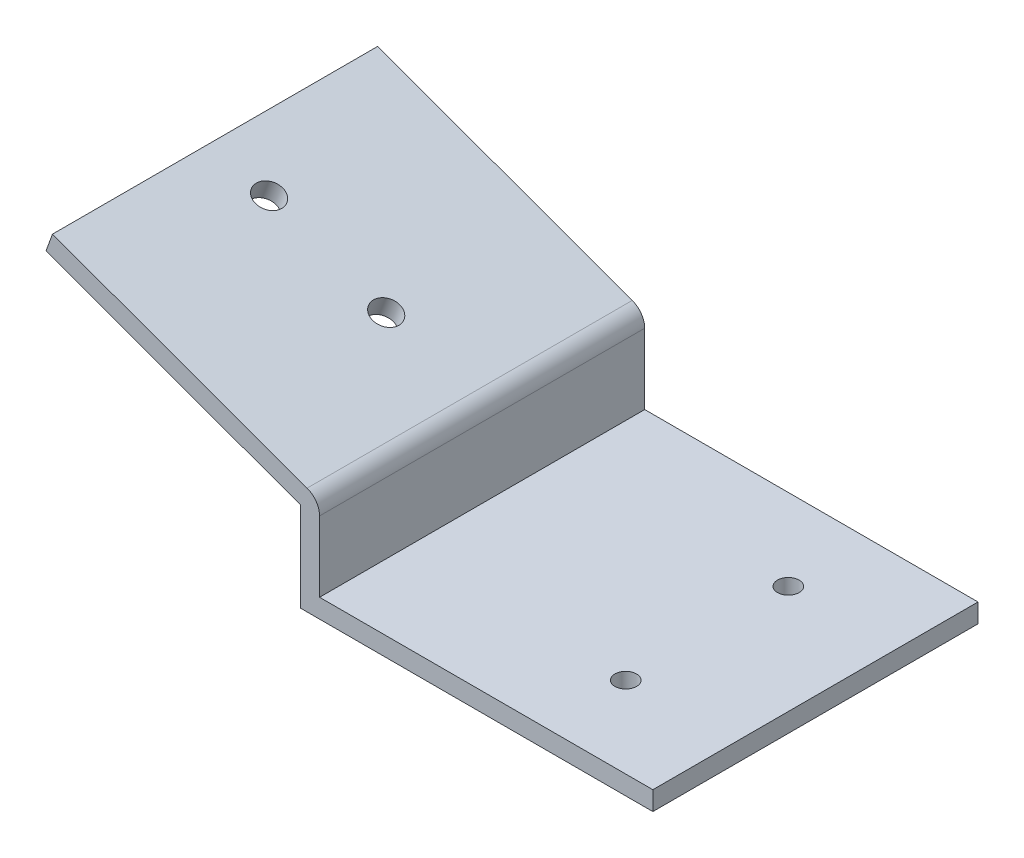
from build123d import *

# Parameters (mm, degrees)
SKETCH1_W           = 65
SKETCH1_H           = 60
BOSS_EXTRUDE1_DEPTH = 3.5
SKETCH2_W           = 3.5
SKETCH2_H           = 60
BOSS_EXTRUDE2_DEPTH = 13
BOSS_EXTRUDE5_DEPTH = 60
SKETCH9_R           = 2
CUT_EXTRUDE1_DEPTH  = 60
SKETCH10_R          = 2.5
CUT_EXTRUDE2_DEPTH  = 60


with BuildPart() as part:
    # Sketch1 → Boss-Extrude1 (new body)
    with BuildSketch(Plane(origin=(0, 0, 0), x_dir=(1, 0, 0), z_dir=(0, 1, 0))):
        with Locations((32.5, -30)):
            Rectangle(SKETCH1_W, SKETCH1_H)
    extrude(amount=BOSS_EXTRUDE1_DEPTH)

    # Sketch2 → Boss-Extrude2 (add)
    with BuildSketch(Plane(origin=(0, 3.5, 0), x_dir=(1, 0, 0), z_dir=(0, 1, 0))):
        with Locations((1.75, -30)):
            Rectangle(SKETCH2_W, SKETCH2_H)
    extrude(amount=BOSS_EXTRUDE2_DEPTH)

    # Sketch7 → Boss-Extrude5 (add)
    with BuildSketch(Plane.XY.offset(60)):
        with BuildLine():
            Line((0, 16.5), (-46.984631039, 33.601007166))
            Line((-46.984631039, 33.601007166), (-45.787560538, 36.889931339))
            Line((-45.787560538, 36.889931339), (1.197070502, 19.788924173))
            ThreePointArc((1.197070502, 19.788924173), (2.867032155, 18.507517527), (3.5, 16.5))
            Line((3.5, 16.5), (3.5, 3.5))
            Line((3.5, 3.5), (65, 3.5))
            Line((65, 3.5), (65, 0))
            Line((65, 0), (0, 0))
            Line((0, 0), (0, 16.5))
        make_face()
    extrude(amount=-BOSS_EXTRUDE5_DEPTH)

    # Sketch9 → Cut-Extrude1 (cut)
    with BuildSketch(Plane(origin=(0, 3.5, 0), x_dir=(1, 0, 0), z_dir=(0, 1, 0))):
        with Locations((45, -15)):
            Circle(SKETCH9_R)
        with Locations((45, -45)):
            Circle(SKETCH9_R)
    extrude(amount=-CUT_EXTRUDE1_DEPTH, mode=Mode.SUBTRACT)

    # Sketch10 → Cut-Extrude2 (cut)
    with BuildSketch(Plane(origin=(6.500068282, 17.858790828, 0), x_dir=(0.939692621, -0.342020143, 0), z_dir=(0.342020143, 0.939692621, 0))):
        with Locations((-44.839233595, -30.181228876)):
            Circle(SKETCH10_R)
        with Locations((-21.839233595, -30.181228876)):
            Circle(SKETCH10_R)
    extrude(amount=-CUT_EXTRUDE2_DEPTH, mode=Mode.SUBTRACT)


solid = part.part
